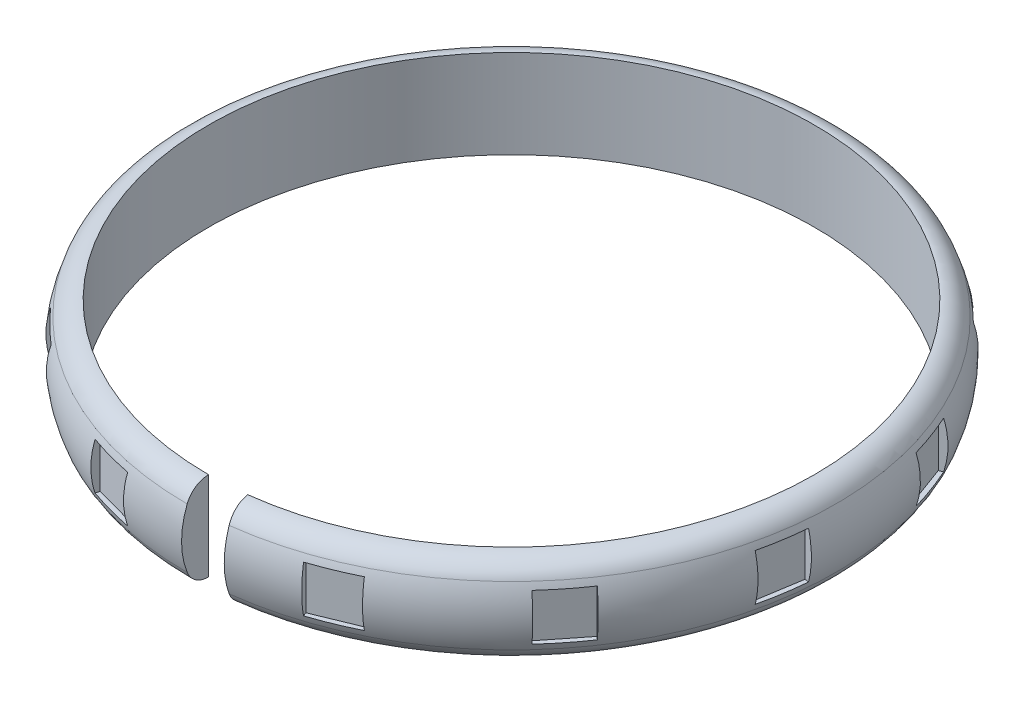
from build123d import *

# Parameters (mm, degrees)
REVOLVE_1_ANGLE     = 353
CUT_EXTRUDE_1_DEPTH = 2.5


with BuildPart() as part:
    # Эскиз1 → Повернуть1 (revolve)
    with BuildSketch(Plane(origin=(0, 0, 0), x_dir=(0, 0, -1), z_dir=(1, 0, 0))):
        with BuildLine():
            Line((-32.5, -4.75), (-32.5, 4.75))
            ThreePointArc((-32.5, 4.75), (-33.892343554, 4.320122191), (-34.8, 3.180133034))
            ThreePointArc((-34.8, 3.180133034), (-35.24868836, 1.618119751), (-35.4, 0))
            ThreePointArc((-35.4, 0), (-35.24868836, -1.618119751), (-34.8, -3.180133034))
            ThreePointArc((-34.8, -3.180133034), (-33.892343554, -4.320122191), (-32.5, -4.75))
        make_face()
    revolve(axis=Axis((0, 39.705655675, 0), (0, -1, 0)), revolution_arc=REVOLVE_1_ANGLE)

    # Эскиз2 → Вырез-Вытянуть1 (cut, symmetric)
    with BuildSketch(Plane(origin=(0, 0, 0), x_dir=(1, 0, 0), z_dir=(0, 1, 0))):
        Polygon((-11.522484756, -32.614909858), (-6.7, -33.935379768), (-7.492281946, -36.828870621), (-12.314766701, -35.508400712), align=None)
        Polygon((-22.452754676, -26.312996931), (-24.559906858, -28.448391433), (-28.118897696, -24.936471129), (-26.011745513, -22.801076627), align=None)
        Polygon((-32.458617484, -11.955674427), (-35.341304043, -12.78640796), (-36.725859931, -7.981930362), (-33.843173372, -7.151196829), align=None)
        Polygon((-34.156539127, 5.46176115), (-37.076922404, 6.148318879), (-35.932659523, 11.015624341), (-33.012276246, 10.329066612), align=None)
        Polygon((-27.111928294, 21.481232371), (-29.322521972, 23.509353569), (-25.942319976, 27.193676365), (-23.731726298, 25.165555168), align=None)
        Polygon((-13.127887423, 32.002477589), (-14.062879288, 34.85305476), (-9.311917335, 36.411374535), (-8.37692547, 33.560797363), align=None)
        Polygon((4.216300145, 34.332532867), (4.796225813, 37.275946909), (9.701915882, 36.309404129), (9.121990214, 33.365990088), align=None)
        Polygon((20.481305165, 27.875009215), (22.427713567, 30.157878973), (26.232496497, 26.913864969), (24.286088094, 24.630995211), align=None)
        Polygon((31.504020417, 14.282741249), (34.318718848, 15.320755094), (36.048741923, 10.629591043), (33.234043493, 9.591577197), align=None)
        Polygon((34.46312827, -2.965263874), (37.425680963, -3.437790638), (36.638136356, -8.375378459), (33.675583664, -7.902851695), align=None)
        Polygon((28.601230664, -19.454295272), (30.953357834, -21.31641712), (27.849821421, -25.23662907), (25.497694251, -23.374507222), align=None)
        Polygon((15.418708827, -30.963905085), (16.558372075, -33.739002864), (11.93320911, -35.638441609), (10.793545863, -32.86334383), align=None)
    extrude(amount=CUT_EXTRUDE_1_DEPTH, both=True, mode=Mode.SUBTRACT)


solid = part.part
